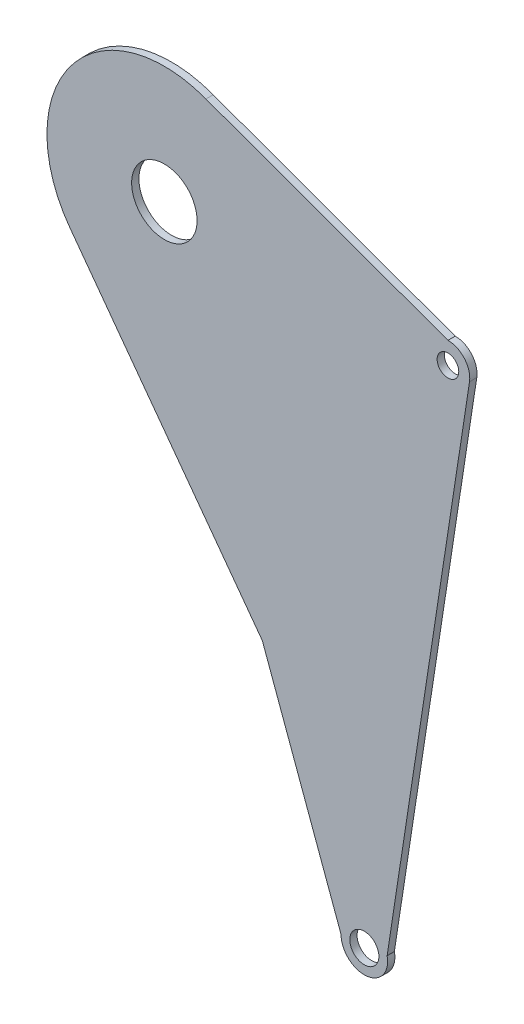
from build123d import *

# Parameters (mm, degrees)
SKETCH1_R           = 6.35
SKETCH1_R_2         = 4.7244
SKETCH1_R_3         = 14.2875
BOSS_EXTRUDE1_DEPTH = 3.175
SKETCH2_R           = 10.16
SKETCH2_R_2         = 9.525
BOSS_EXTRUDE2_DEPTH = 3.175
BOSS_EXTRUDE3_DEPTH = 3.175


with BuildPart() as part:
    # Sketch1 → Boss-Extrude1 (new body)
    with BuildSketch(Plane.XY):
        with BuildLine():
            Line((123.825, 9.525), (50.373687682, 9.525))
            ThreePointArc((50.373687682, 9.525), (-42.021955485, 29.366465449), (8.37139721, -50.578194358))
            Line((8.37139721, -50.578194358), (78.367942069, -241.795763571))
            ThreePointArc((78.367942069, -241.795763571), (88.258712803, -247.99942994), (96.727824138, -239.962827716))
            Line((96.727824138, -239.962827716), (133.240324138, -1.441282895))
            ThreePointArc((133.240324138, -1.441282895), (131.051819652, 6.204732284), (123.825, 9.525))
        make_face()
        with Locations((87.3125, -238.521544821)):
            Circle(SKETCH1_R, mode=Mode.SUBTRACT)
        with Locations((123.825, 0)):
            Circle(SKETCH1_R_2, mode=Mode.SUBTRACT)
        Circle(SKETCH1_R_3, mode=Mode.SUBTRACT)
    extrude(amount=BOSS_EXTRUDE1_DEPTH)

    # Sketch2 → Boss-Extrude2 (add)
    with BuildSketch(Plane(origin=(0, 0, 0), x_dir=(-1, 0, 0), z_dir=(0, 0, -1))):
        with Locations((-87.3125, -238.521544821)):
            Circle(SKETCH2_R)
        with Locations((-87.3125, -238.521544821)):
            Circle(SKETCH2_R_2, mode=Mode.SUBTRACT)
    extrude(amount=-BOSS_EXTRUDE2_DEPTH)

    # Sketch3 → Boss-Extrude3 (add)
    with BuildSketch(Plane(origin=(0, 0, 0), x_dir=(-1, 0, 0), z_dir=(0, 0, -1))):
        with BuildLine():
            ThreePointArc((-50.373687682, 9.525), (-39.281923062, 32.941835958), (-18.155694858, 47.943766852))
            Line((-18.155694858, 47.943766852), (-123.825, 9.525))
            Line((-123.825, 9.525), (-50.373687682, 9.525))
        make_face()
        with BuildLine():
            Line((-8.37139721, -50.578194358), (-42.762000357, -144.526939268))
            Line((-42.762000357, -144.526939268), (41.245405611, -30.447504852))
            ThreePointArc((41.245405611, -30.447504852), (19.273979145, -47.505239328), (-8.37139721, -50.578194358))
        make_face()
    extrude(amount=-BOSS_EXTRUDE3_DEPTH)


solid = part.part
